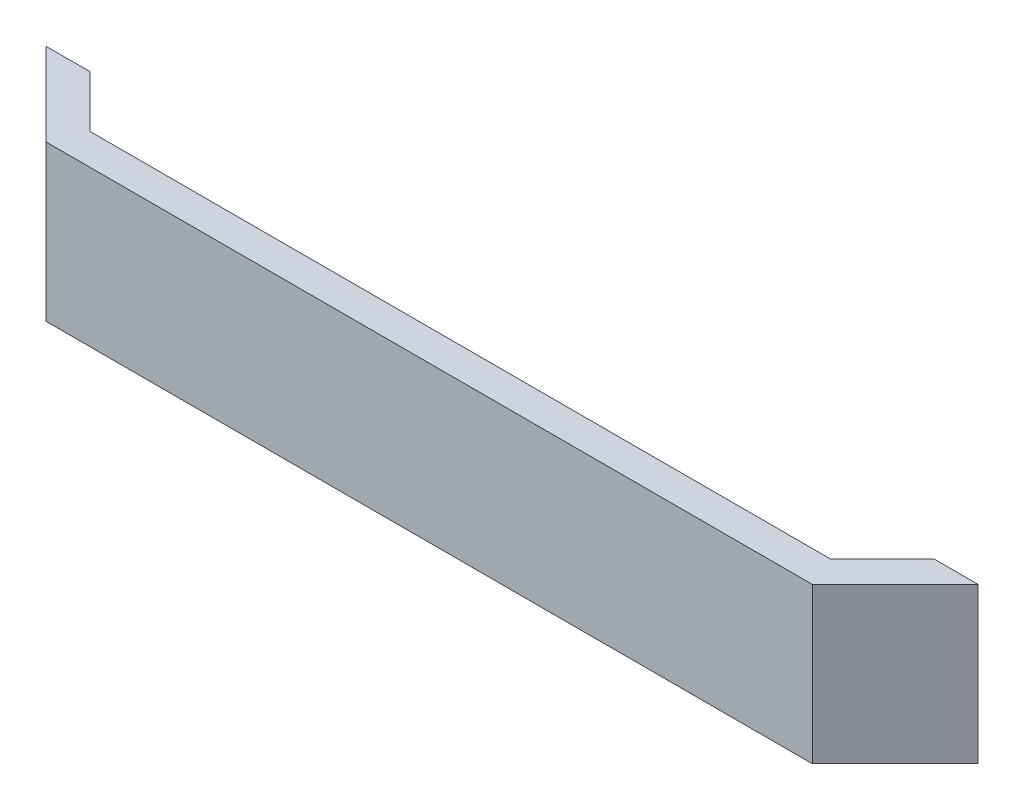
from build123d import *

# Parameters (mm, degrees)
SALIENTE_EXTRUIR1_DEPTH = 15


with BuildPart() as part:
    # Croquis1 → Saliente-Extruir1 (new body)
    with BuildSketch(Plane(origin=(0, 0, 0), x_dir=(1, 0, 0), z_dir=(0, 1, 0))):
        Polygon((-37, 0), (37, 0), (45, 8), (40.757359313, 8), (35.757359313, 3), (-35.757359313, 3), (-40.757359313, 8), (-45, 8), align=None)
    extrude(amount=SALIENTE_EXTRUIR1_DEPTH)


solid = part.part
